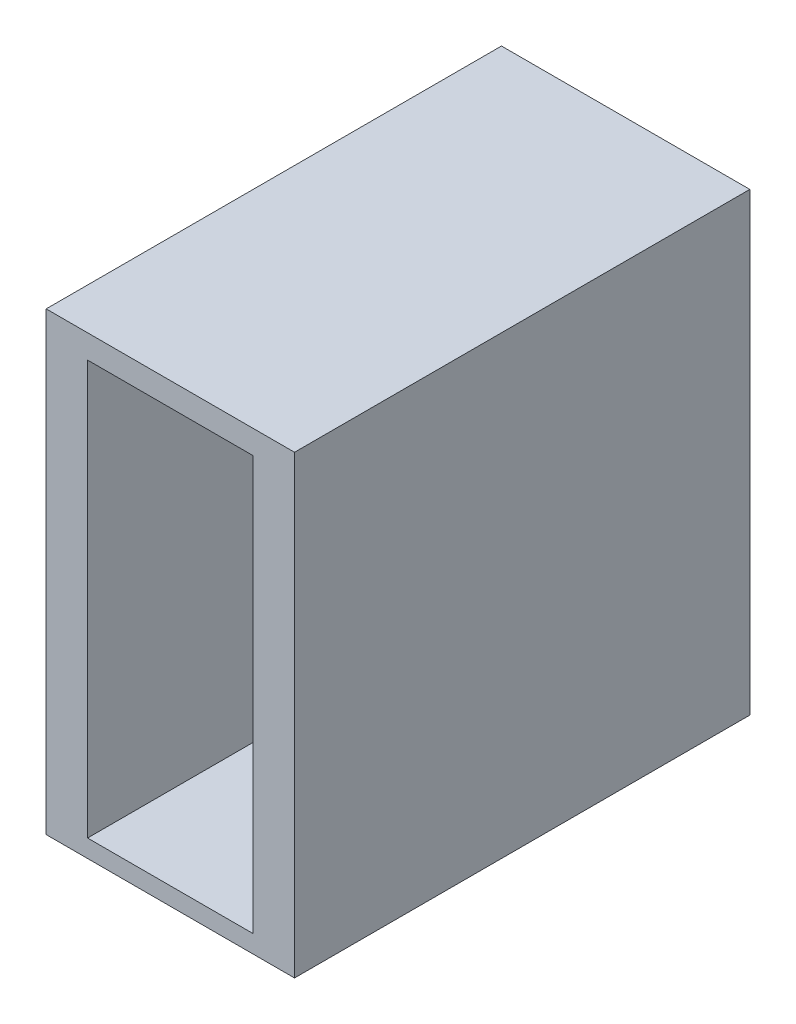
from build123d import *

# Parameters (mm, degrees)
SKETCH2_W           = 12
SKETCH2_H           = 22
BOSS_EXTRUDE1_DEPTH = 22
SKETCH4_W           = 8
SKETCH4_H           = 20
CUT_EXTRUDE1_DEPTH  = 18
CUT_EXTRUDE2_DEPTH  = 10


with BuildPart() as part:
    # Sketch2 → Boss-Extrude1 (new body)
    with BuildSketch(Plane(origin=(0, 0, 0), x_dir=(1, 0, 0), z_dir=(0, 1, 0))):
        with Locations((6, 11)):
            Rectangle(SKETCH2_W, SKETCH2_H)
    extrude(amount=BOSS_EXTRUDE1_DEPTH)

    # Sketch4 → Cut-Extrude1 (cut)
    with BuildSketch(Plane.XY):
        with Locations((6, 10.85774702)):
            Rectangle(SKETCH4_W, SKETCH4_H)
    extrude(amount=-CUT_EXTRUDE1_DEPTH, mode=Mode.SUBTRACT)

    # Sketch6 → Cut-Extrude2 (cut)
    with BuildSketch(Plane.XY.offset(-18)):
        with BuildLine():
            Line((5, 2.55774702), (5, 19.15774702))
            ThreePointArc((5, 19.15774702), (6, 20.15774702), (7, 19.15774702))
            Line((7, 19.15774702), (7, 2.55774702))
            ThreePointArc((7, 2.55774702), (6, 1.55774702), (5, 2.55774702))
        make_face()
    extrude(amount=-CUT_EXTRUDE2_DEPTH, mode=Mode.SUBTRACT)


solid = part.part
